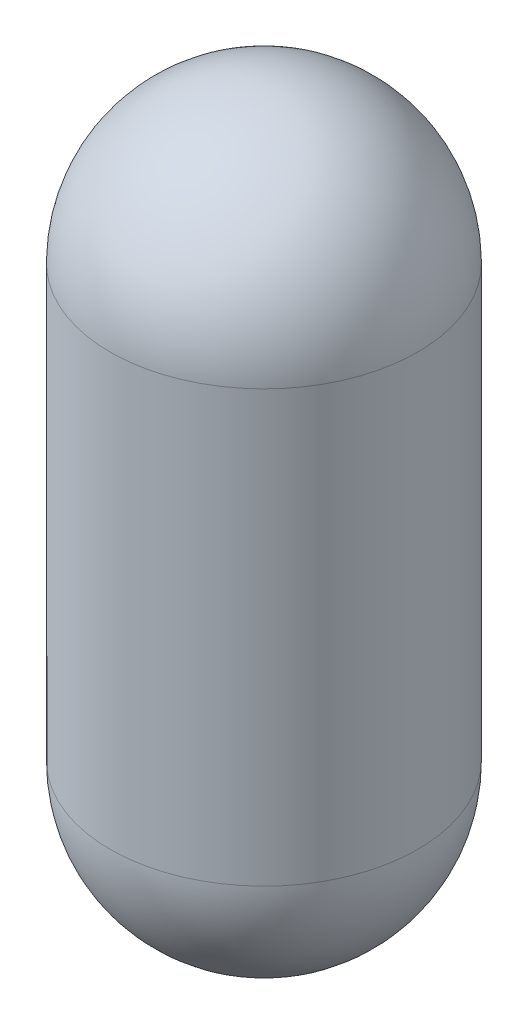
from build123d import *


with BuildPart() as part:
    # Sketch1 → Revolve1 (revolve)
    with BuildSketch(Plane.XY):
        with BuildLine():
            Line((0, 0), (0, 350))
            ThreePointArc((0, 350), (36.611652352, 438.388347648), (125, 475))
            Line((125, 475), (125, 465))
            ThreePointArc((125, 465), (43.682720164, 431.317279836), (10, 350))
            Line((10, 350), (10, 0))
            ThreePointArc((10, 0), (43.682720164, -81.317279836), (125, -115))
            Line((125, -115), (125, -125))
            ThreePointArc((125, -125), (36.611652352, -88.388347648), (0, 0))
        make_face()
    revolve(axis=Axis((125, 475, 0), (0, -1, 0)))


solid = part.part
